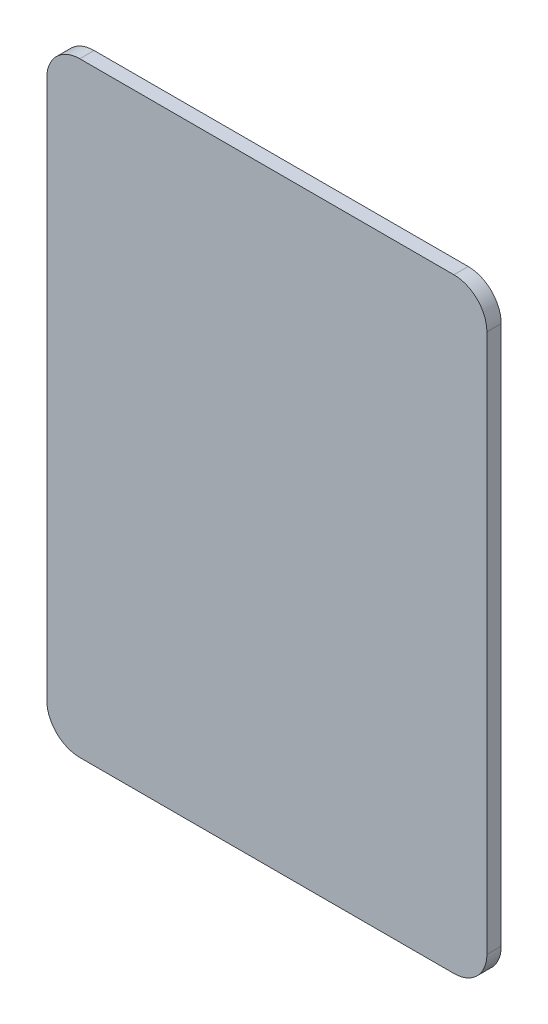
from build123d import *

# Parameters (mm, degrees)
SKETCH1_W           = 55
SKETCH1_H           = 40
BOSS_EXTRUDE1_DEPTH = 1.3
FILLET1_R           = 3


with BuildPart() as part:
    # Sketch1 → Boss-Extrude1 (new body)
    with BuildSketch(Plane(origin=(0, 0, 0), x_dir=(0, 1, 0), z_dir=(0, 0, 1))):
        Rectangle(SKETCH1_W, SKETCH1_H)
    extrude(amount=BOSS_EXTRUDE1_DEPTH)

    # Fillet1
    fillet1_edges = [part.edges().sort_by_distance(p)[0] for p in [
        (20, 27.5, 0.65),
        (20, -27.5, 0.65),
        (-20, -27.5, 0.65),
        (-20, 27.5, 0.65),
    ]]
    fillet(fillet1_edges, radius=FILLET1_R)


solid = part.part
